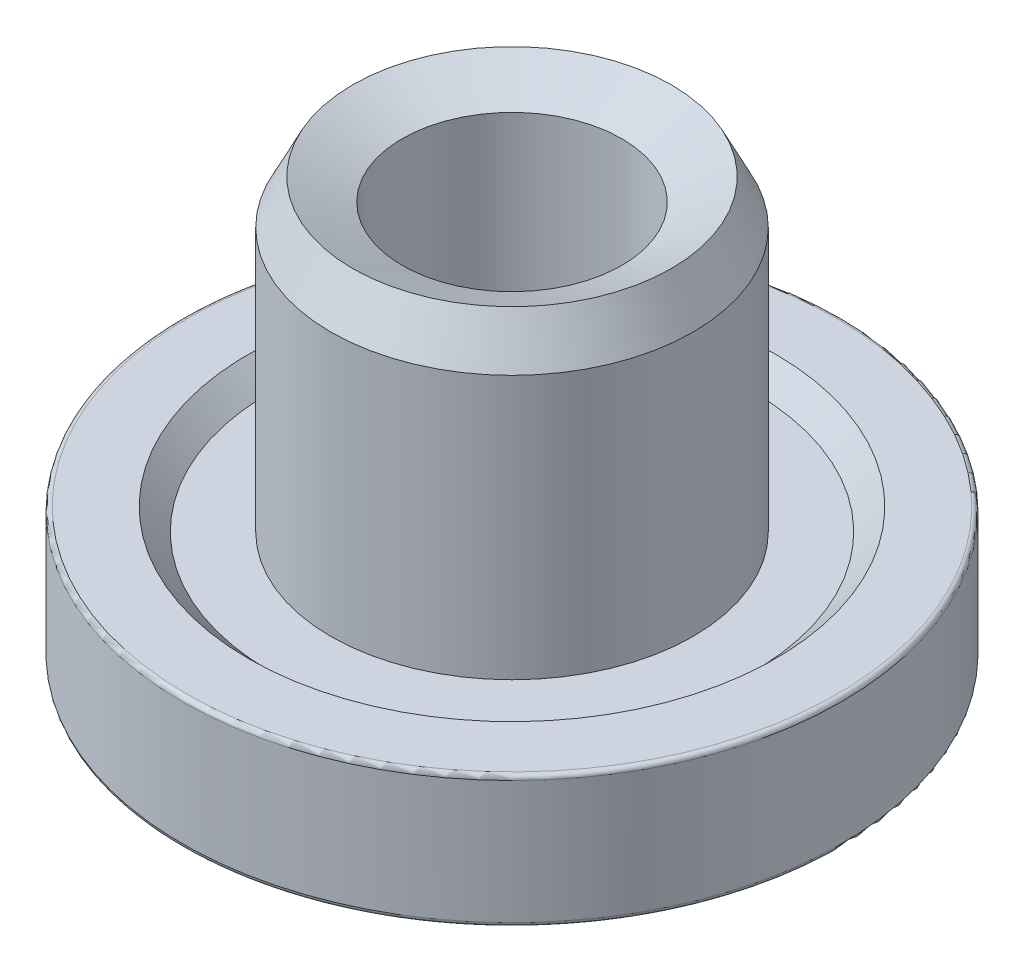
from build123d import *

# Parameters (mm, degrees)
HEADFILLET_R = 0.1


with BuildPart() as part:
    # ProfileS → Profile (revolve)
    with BuildSketch(Plane.XY, mode=Mode.PRIVATE) as profile_sk:
        Polygon((2.5, 0), (7.5, 0), (7.5, 3), (6, 3), (5.5, 2.5), (4.125, 2.5), (4.125, 8.5), (3.625, 9.5), (2.5, 9), align=None)
    revolve(profile_sk.sketch.rotate(Axis((0, 0, 0), (0, 1, 0)), 90), axis=Axis((0, 0, 0), (0, 1, 0)))

    # HeadFillet
    headfillet_edges = [part.edges().sort_by_distance(p)[0] for p in [
        (0, 3, 7.5),
        (0, 0, 7.5),
    ]]
    fillet(headfillet_edges, radius=HEADFILLET_R)


solid = part.part
